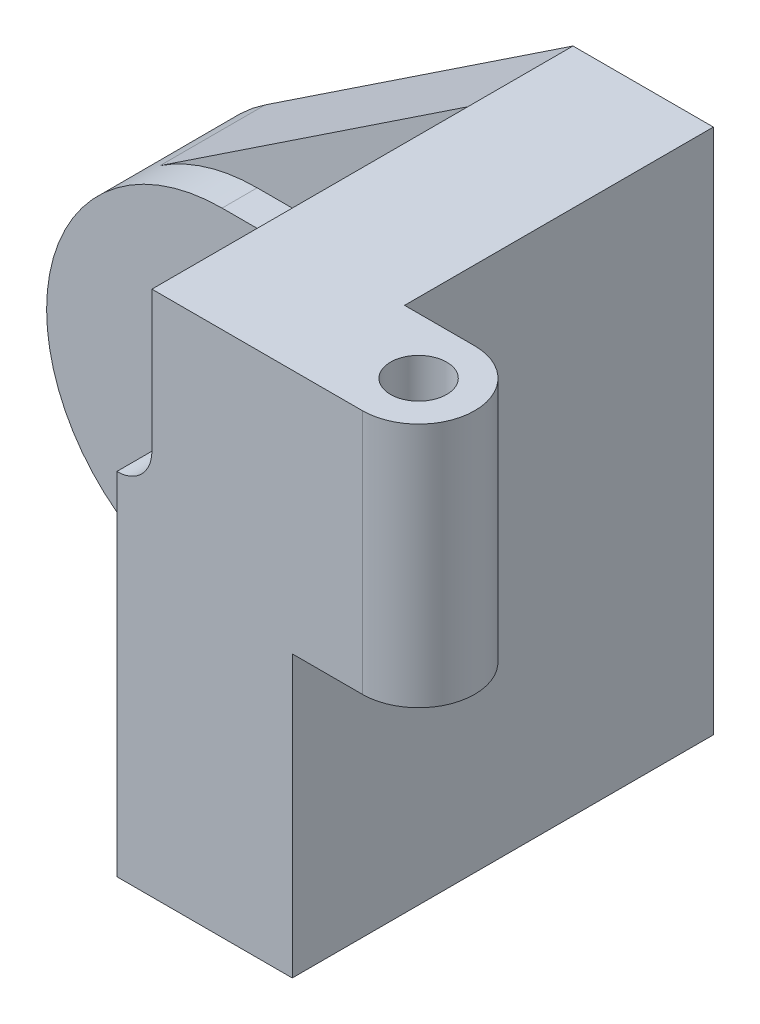
from build123d import *

# Parameters (mm, degrees)
SKETCH1_R           = 10
BOSS_EXTRUDE1_DEPTH = 20
BOSS_EXTRUDE2_START = 20
BOSS_EXTRUDE2_DEPTH = 40
BOSS_EXTRUDE3_DEPTH = 15
SKETCH2_R           = 4
BOSS_EXTRUDE4_DEPTH = 35


with BuildPart() as part:
    # Sketch1 → Boss-Extrude1 (new body)
    with BuildSketch(Plane.XY):
        with BuildLine():
            ThreePointArc((0, -25), (-25, 0), (0, 25))
            Line((0, 25), (25, 25))
            Line((25, 25), (25, -25))
            Line((25, -25), (0, -25))
        make_face()
        Circle(SKETCH1_R, mode=Mode.SUBTRACT)
        with BuildLine():
            ThreePointArc((30, 30), (28.535533906, 26.464466094), (25, 25))
            Line((25, 25), (25, -25))
            Line((25, -25), (50, -25))
            Line((50, -25), (50, 15))
            Line((50, 15), (50, 50))
            Line((50, 50), (30, 50))
            Line((30, 50), (30, 30))
        make_face()
    extrude(amount=BOSS_EXTRUDE1_DEPTH)

    # Sketch1_3 → Boss-Extrude2 (add)
    with BuildSketch(Plane.XY.offset(BOSS_EXTRUDE2_START)):
        with BuildLine():
            ThreePointArc((30, 30), (28.535533906, 26.464466094), (25, 25))
            Line((25, 25), (25, -25))
            Line((25, -25), (50, -25))
            Line((50, -25), (50, 15))
            Line((50, 15), (50, 50))
            Line((50, 50), (30, 50))
            Line((30, 50), (30, 30))
        make_face()
    extrude(amount=BOSS_EXTRUDE2_DEPTH)

    # Sketch1_4 → Boss-Extrude3 (add)
    with BuildSketch(Plane.XY):
        with BuildLine():
            ThreePointArc((-13.852304693, 20.811382816), (-7.2358631, 23.929945365), (0, 25))
            Line((0, 25), (25, 25))
            ThreePointArc((25, 25), (28.535533906, 26.464466094), (30, 30))
            Line((30, 30), (30, 50))
            Line((30, 50), (-13.852304693, 20.811382816))
        make_face()
    extrude(amount=BOSS_EXTRUDE3_DEPTH)

    # Sketch2 → Boss-Extrude4 (add)
    with BuildSketch(Plane(origin=(0, 50, 0), x_dir=(1, 0, 0), z_dir=(0, 1, 0))):
        with BuildLine():
            Line((60, -44), (50, -44))
            Line((50, -44), (50, -60))
            Line((50, -60), (60, -60))
            ThreePointArc((60, -60), (68, -52), (60, -44))
        make_face()
        with Locations((60, -52)):
            Circle(SKETCH2_R, mode=Mode.SUBTRACT)
    extrude(amount=-BOSS_EXTRUDE4_DEPTH)


solid = part.part
